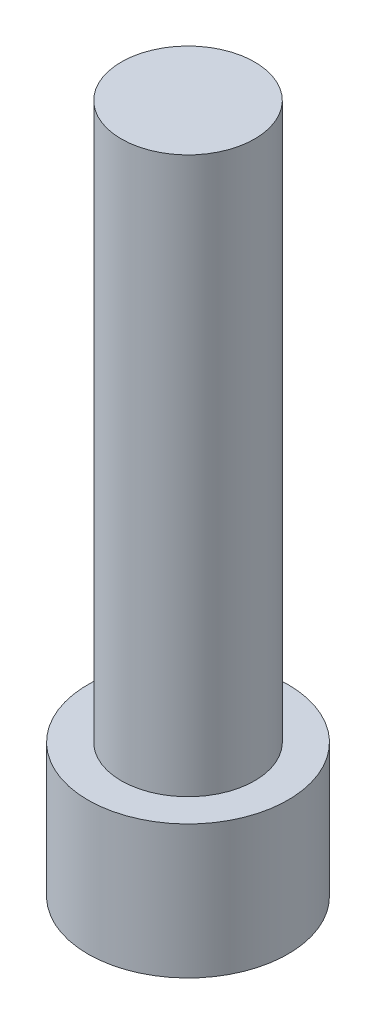
from build123d import *

# Parameters (mm, degrees)
SKETCH1_R           = 9
BOSS_EXTRUDE1_DEPTH = 12
SKETCH2_R           = 6
BOSS_EXTRUDE2_DEPTH = 50


with BuildPart() as part:
    # Sketch1 → Boss-Extrude1 (new body)
    with BuildSketch(Plane(origin=(0, 0, 0), x_dir=(1, 0, 0), z_dir=(0, 1, 0))):
        Circle(SKETCH1_R)
    extrude(amount=BOSS_EXTRUDE1_DEPTH)

    # Sketch2 → Boss-Extrude2 (add)
    with BuildSketch(Plane(origin=(0, 12, 0), x_dir=(1, 0, 0), z_dir=(0, 1, 0))):
        Circle(SKETCH2_R)
    extrude(amount=BOSS_EXTRUDE2_DEPTH)


solid = part.part
